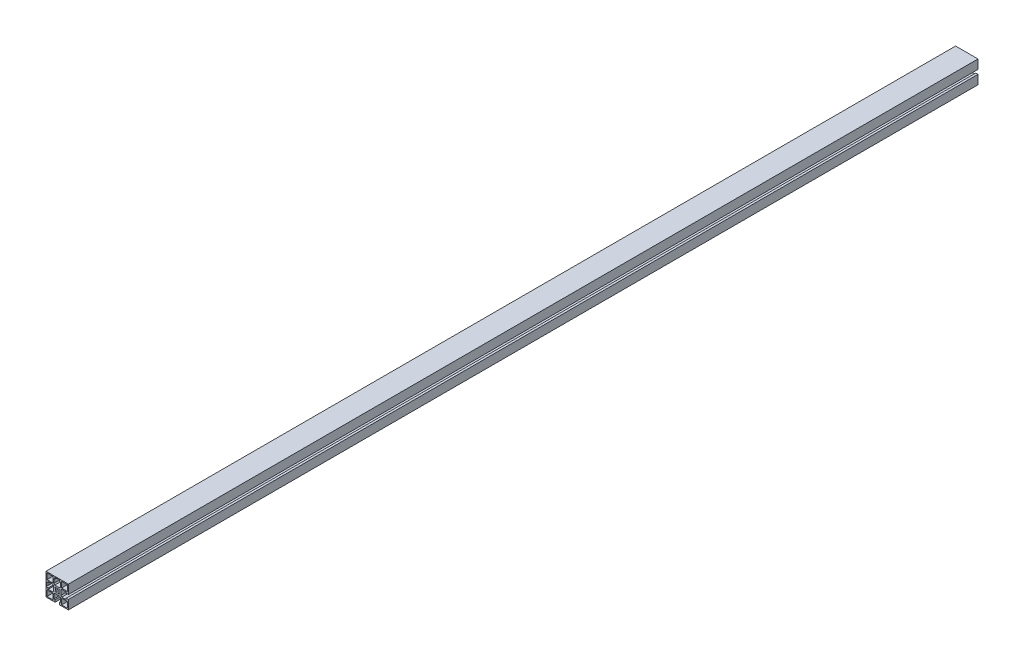
from build123d import *

# Parameters (mm, degrees)
SKETCH1_W           = 11.699975178
SKETCH1_H           = 11.699996949
SKETCH1_W_2         = 11.699990436
SKETCH1_H_2         = 11.699981689
SKETCH1_W_3         = 11.699990437
SKETCH1_H_3         = 11.699975177
SKETCH1_W_4         = 11.699981689
SKETCH1_H_4         = 11.699990436
BOSS_EXTRUDE1_DEPTH = 1828.8


with BuildPart() as part:
    # Sketch1 → Boss-Extrude1 (new body)
    with BuildSketch(Plane.XY):
        Polygon((22.500515052, 22.499297556), (-22.499484399, 22.499298105), (-22.499484948, -22.500701346), (-4.249491942, -22.500701568), (-4.249491942, -22.200733242), (-4.24949208, -18.000719999), (-6.799479919, -18.000719999), (-6.799480207, -9.200732353), (-4.799480391, -7.200732362), (4.800525817, -7.200732047), (6.8005258, -9.200731855), (6.800526088, -18.000720263), (4.250507877, -18.000720263), (4.250508015, -22.200733153), (4.250508015, -22.500701672), (22.500514502, -22.500701895), (22.500514725, -4.250714302), (22.200520351, -4.250714302), (18.000507108, -4.25071444), (18.000507108, -6.800702279), (9.200519462, -6.800702567), (7.200519471, -4.800702751), (7.200519156, 4.799303458), (9.200518964, 6.79930344), (18.000507424, 6.799303729), (18.000507424, 4.249285514), (22.200520261, 4.249285652), (22.500514829, 4.249285652), align=None)
        with BuildLine():
            Line((-4.249491247, 17.999291576), (-4.249490956, 22.199304807))
            Line((-4.249490956, 22.199304807), (-3.949472548, 22.199304807))
            Line((-3.949472548, 22.199304807), (-3.481695222, 21.73152644))
            ThreePointArc((-3.481695222, 21.73152644), (-2.670636178, 21.189593132), (-1.713926324, 20.999291428))
            Line((-1.713926324, 20.999291428), (1.714975167, 20.999291428))
            ThreePointArc((1.714975167, 20.999291428), (2.671722509, 21.189608628), (3.482801459, 21.731583767))
            Line((3.482801459, 21.731583767), (3.950490798, 22.199304487))
            Line((3.950490798, 22.199304487), (4.250509108, 22.199304487))
            Line((4.250509108, 22.199304487), (4.250508817, 17.999291575))
            Line((4.250508817, 17.999291575), (6.800527063, 17.999291575))
            Line((6.800527063, 17.999291575), (6.800526453, 9.199302988))
            Line((6.800526453, 9.199302988), (4.800526064, 7.199302969))
            Line((4.800526064, 7.199302969), (-4.799479817, 7.199303635))
            Line((-4.799479817, 7.199303635), (-6.799479854, 9.199304042))
            Line((-6.799479854, 9.199304042), (-6.799479244, 17.999291576))
            Line((-6.799479244, 17.999291576), (-4.249491247, 17.999291576))
        make_face(mode=Mode.SUBTRACT)
        with BuildLine():
            Line((-17.99949762, -4.250714253), (-22.199510799, -4.250714391))
            Line((-22.199510799, -4.250714391), (-22.199510799, -3.950696126))
            Line((-22.199510799, -3.950696126), (-21.731790056, -3.48300681))
            ThreePointArc((-21.731790056, -3.48300681), (-21.189814855, -2.671927844), (-20.999497617, -1.71518046))
            Line((-20.999497617, -1.71518046), (-20.999497617, 1.713721031))
            ThreePointArc((-20.999497617, 1.713721031), (-21.189799286, 2.670430863), (-21.731732544, 3.481489907))
            Line((-21.731732544, 3.481489907), (-22.199510888, 3.949267256))
            Line((-22.199510888, 3.949267256), (-22.199510888, 4.249285566))
            Line((-22.199510888, 4.249285566), (-17.999497356, 4.249285704))
            Line((-17.999497356, 4.249285704), (-17.999497356, 6.79927354))
            Line((-17.999497356, 6.79927354), (-9.199509947, 6.799273828))
            Line((-9.199509947, 6.799273828), (-7.199509956, 4.799274012))
            Line((-7.199509956, 4.799274012), (-7.199509641, -4.800732197))
            Line((-7.199509641, -4.800732197), (-9.199509449, -6.800732179))
            Line((-9.199509449, -6.800732179), (-17.99949762, -6.800732468))
            Line((-17.99949762, -6.800732468), (-17.99949762, -4.250714253))
        make_face(mode=Mode.SUBTRACT)
        with Locations((-14.649542346, -14.650709384)):
            Rectangle(SKETCH1_W, SKETCH1_H, mode=Mode.SUBTRACT)
        with Locations((14.65050626, -14.650767962)):
            Rectangle(SKETCH1_W_2, SKETCH1_H_2, mode=Mode.SUBTRACT)
        with BuildLine():
            Line((-3.181457266, -4.596908447), (-4.595670829, -3.182694885))
            Line((-4.595670829, -3.182694885), (-3.26221457, -1.849238626))
            ThreePointArc((-3.26221457, -1.849238626), (-3.749476751, -0.00071437), (-3.26221457, 1.847809887))
            Line((-3.26221457, 1.847809887), (-4.595670829, 3.181266146))
            Line((-4.595670829, 3.181266146), (-3.181457266, 4.595479708))
            Line((-3.181457266, 4.595479708), (-1.848001007, 3.262023449))
            ThreePointArc((-1.848001007, 3.262023449), (0.000523249, 3.74928563), (1.849047505, 3.262023449))
            Line((1.849047505, 3.262023449), (3.182503764, 4.595479708))
            Line((3.182503764, 4.595479708), (4.596717327, 3.181266146))
            Line((4.596717327, 3.181266146), (3.263261068, 1.847809887))
            ThreePointArc((3.263261068, 1.847809887), (3.750523249, -0.00071437), (3.263261068, -1.849238626))
            Line((3.263261068, -1.849238626), (4.596717327, -3.182694885))
            Line((4.596717327, -3.182694885), (3.182503764, -4.596908447))
            Line((3.182503764, -4.596908447), (1.849047505, -3.263452188))
            ThreePointArc((1.849047505, -3.263452188), (0.000523249, -3.75071437), (-1.848001007, -3.263452188))
            Line((-1.848001007, -3.263452188), (-3.181457266, -4.596908447))
        make_face(mode=Mode.SUBTRACT)
        with Locations((-14.64949028, 14.649335967)):
            Rectangle(SKETCH1_W_3, SKETCH1_H_3, mode=Mode.SUBTRACT)
        with Locations((14.650561583, 14.6492839)):
            Rectangle(SKETCH1_W_4, SKETCH1_H_4, mode=Mode.SUBTRACT)
    extrude(amount=BOSS_EXTRUDE1_DEPTH)


solid = part.part
